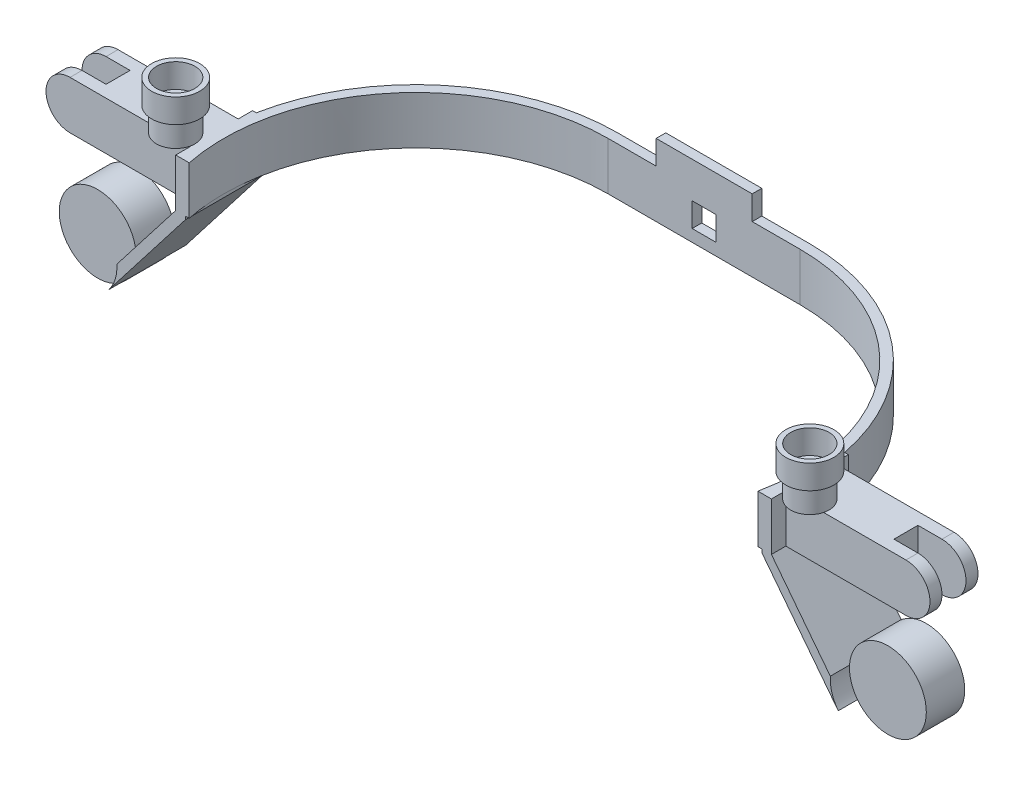
from build123d import *

# Parameters (mm, degrees)
EXTRUDE_1_DEPTH           = 20
SKETCH_18_W               = 10
SKETCH_18_H               = 10
CUT_EXTRUDE_6_DEPTH       = 10
SKETCH_20_W               = 40
SKETCH_20_H               = 4
EXTRUDE_5_DEPTH           = 10
SKETCH_22_R               = 8
EXTRUDE_7_DEPTH           = 10
EXTRUDE_7_2_DEPTH         = 10
SKETCH_23_R               = 10
SKETCH_23_R_2             = 8
EXTRUDE_8_DEPTH           = 10
EXTRUDE_8_2_DEPTH         = 10
SKETCH_8_W                = 4
SKETCH_8_H                = 32
SKETCH_11_W               = 4
SKETCH_11_H               = 32
SKETCH_25_W               = 246.903686524
SKETCH_25_H               = 75.06139437
CUT_EXTRUDE_7_DEPTH       = 30
SKETCH_26_W               = 20
SKETCH_26_H               = 20
EXTRUDE_9_DEPTH           = 60
SKETCH_28_W               = 20
SKETCH_28_H               = 20
EXTRUDE_10_DEPTH          = 60
CUT_EXTRUDE_8_DEPTH       = 60
SKETCH_29_W               = 20
SKETCH_29_H               = 25.723700811
SKETCH_29_H_2             = 33.540144271
CUT_EXTRUDE_9_DEPTH       = 5
SKETCH_30_R               = 16
CUT_EXTRUDE_10_DEPTH      = 19
CUT_EXTRUDE_10_DEPTH_BACK = 85
SKETCH_31_R               = 16
EXTRUDE_11_DEPTH          = 8


with BuildPart() as part:
    # 草图2 → 凸台-拉伸1 (new body)
    with BuildSketch(Plane(origin=(0, 0, 0), x_dir=(1, 0, 0), z_dir=(0, 1, 0))):
        with BuildLine():
            Line((-40, 84), (40, 84))
            ThreePointArc((40, 84), (124, 0), (40, -84))
            Line((40, -84), (-40, -84))
            ThreePointArc((-40, -84), (-124, 0), (-40, 84))
        make_face()
        with BuildLine():
            Line((-40, 80), (40, 80))
            ThreePointArc((40, 80), (120, 0), (40, -80))
            Line((40, -80), (-40, -80))
            ThreePointArc((-40, -80), (-120, 0), (-40, 80))
        make_face(mode=Mode.SUBTRACT)
    extrude(amount=EXTRUDE_1_DEPTH)

    # 草图18 → 切除-拉伸6 (cut)
    with BuildSketch(Plane(origin=(0, 0, -84), x_dir=(-1, 0, 0), z_dir=(0, 0, -1))):
        with Locations((0, 10)):
            Rectangle(SKETCH_18_W, SKETCH_18_H)
    extrude(amount=-CUT_EXTRUDE_6_DEPTH, mode=Mode.SUBTRACT)

    # 草图20 → 凸台-拉伸5 (add)
    with BuildSketch(Plane(origin=(0, 20, 0), x_dir=(1, 0, 0), z_dir=(0, 1, 0))):
        with Locations((0, 82)):
            Rectangle(SKETCH_20_W, SKETCH_20_H)
    extrude(amount=EXTRUDE_5_DEPTH)

    # 扫描1: sweep along a path in 草图9
    with BuildLine(Plane.XY) as sweep_1_path:
        Line((-124, 20), (-124, 0))
        Line((-124, 0), (-155, -40))
    # 草图8 → 扫描1 (sweep)
    with BuildSketch(Plane(origin=(0, 20, 0), x_dir=(1, 0, 0), z_dir=(0, 1, 0))):
        with Locations((-122, 0)):
            Rectangle(SKETCH_8_W, SKETCH_8_H)
    sweep(path=sweep_1_path.line, transition=Transition.RIGHT)

    # 扫描2: sweep along a path in 草图24
    with BuildLine(Plane.XY) as sweep_2_path:
        Line((124, 20), (124, 0))
        Line((124, 0), (155, -40))
    # 草图11 → 扫描2 (sweep)
    with BuildSketch(Plane(origin=(0, 20, 0), x_dir=(1, 0, 0), z_dir=(0, 1, 0))):
        with Locations((122, 0)):
            Rectangle(SKETCH_11_W, SKETCH_11_H)
    sweep(path=sweep_2_path.line, transition=Transition.RIGHT)

    # 草图25 → 切除-拉伸7 (cut)
    with BuildSketch(Plane(origin=(0, 20, 0), x_dir=(1, 0, 0), z_dir=(0, 1, 0))):
        with Locations((0.98973075, -53.530697185)):
            Rectangle(SKETCH_25_W, SKETCH_25_H)
    extrude(amount=-CUT_EXTRUDE_7_DEPTH, mode=Mode.SUBTRACT)



with BuildPart() as body_2:
    # 草图22 → 凸台-拉伸7 (new body)
    with BuildSketch(Plane(origin=(0, 20, 0), x_dir=(1, 0, 0), z_dir=(0, 1, 0))):
        with Locations((-132, -8)):
            Circle(SKETCH_22_R)
    extrude(amount=EXTRUDE_7_DEPTH)


with BuildPart() as body_3:
    # 草图22 → Extrude 7 2 (new body)
    with BuildSketch(Plane(origin=(0, 20, 0), x_dir=(1, 0, 0), z_dir=(0, 1, 0))):
        with Locations((132, -8)):
            Circle(SKETCH_22_R)
    extrude(amount=EXTRUDE_7_2_DEPTH)


with BuildPart() as body_4:
    # 草图23 → 凸台-拉伸8 (new body)
    with BuildSketch(Plane(origin=(0, 30, 0), x_dir=(1, 0, 0), z_dir=(0, 1, 0))):
        with Locations((-132, -8)):
            Circle(SKETCH_23_R)
        with Locations((-132, -8)):
            Circle(SKETCH_23_R_2, mode=Mode.SUBTRACT)
    extrude(amount=EXTRUDE_8_DEPTH)


with BuildPart() as body_5:
    # 草图23 → Extrude 8 2 (new body)
    with BuildSketch(Plane(origin=(0, 30, 0), x_dir=(1, 0, 0), z_dir=(0, 1, 0))):
        with Locations((132, -8)):
            Circle(SKETCH_23_R)
        with Locations((132, -8)):
            Circle(SKETCH_23_R_2, mode=Mode.SUBTRACT)
    extrude(amount=EXTRUDE_8_2_DEPTH)


with BuildPart() as part_1:
    add(part.part)

    add(body_2.part)  # 凸台-拉伸9 merges body 2
    # 草图26 → 凸台-拉伸9 (add)
    with BuildSketch(Plane.ZY.offset(124)):
        with Locations((0, 10)):
            Rectangle(SKETCH_26_W, SKETCH_26_H)
    extrude(amount=EXTRUDE_9_DEPTH)


    add(body_3.part)  # 凸台-拉伸10 merges body 3
    # 草图28 → 凸台-拉伸10 (add)
    with BuildSketch(Plane(origin=(124, 0, 0), x_dir=(0, 0, -1), z_dir=(1, 0, 0))):
        with Locations((0, 10)):
            Rectangle(SKETCH_28_W, SKETCH_28_H)
    extrude(amount=EXTRUDE_10_DEPTH)

    # 草图27 → 切除-拉伸8 (cut)
    with BuildSketch(Plane.XY.offset(10)):
        with BuildLine():
            Line((-174, 20), (-189, 20))
            Line((-189, 20), (-189, 0))
            Line((-189, 0), (-174, 0))
            ThreePointArc((-174, 0), (-184, 10), (-174, 20))
        make_face()
        with BuildLine():
            Line((174, 20), (191.961940959, 20))
            Line((191.961940959, 20), (191.961940959, 0))
            Line((191.961940959, 0), (174, 0))
            ThreePointArc((174, 0), (184, 10), (174, 20))
        make_face()
    extrude(amount=-CUT_EXTRUDE_8_DEPTH, mode=Mode.SUBTRACT)

    # 草图29 → 切除-拉伸9 (cut, symmetric)
    with BuildSketch(Plane.XY):
        with Locations((-174, 8.750781757)):
            Rectangle(SKETCH_29_W, SKETCH_29_H)
        with Locations((174, 7.12005993)):
            Rectangle(SKETCH_29_W, SKETCH_29_H_2)
    extrude(amount=CUT_EXTRUDE_9_DEPTH, both=True, mode=Mode.SUBTRACT)

    # 草图30 → 切除-拉伸10 (cut, two sides)
    with BuildSketch(Plane.XY) as cut_extrude_10_sk:
        with Locations((-164.484980626, -32.649140015)):
            Circle(SKETCH_30_R)
        with Locations((164.484980626, -32.649140015)):
            Circle(SKETCH_30_R)
    extrude(amount=CUT_EXTRUDE_10_DEPTH, mode=Mode.SUBTRACT)
    extrude(cut_extrude_10_sk.sketch, amount=-CUT_EXTRUDE_10_DEPTH_BACK, mode=Mode.SUBTRACT)

    # 草图31 → 凸台-拉伸11 (add, symmetric)
    with BuildSketch(Plane.XY):
        with Locations((-164.484980626, -32.649140015)):
            Circle(SKETCH_31_R)
        with Locations((164.484980626, -32.649140015)):
            Circle(SKETCH_31_R)
    extrude(amount=EXTRUDE_11_DEPTH, both=True)


solid = Compound([body_4.part, body_5.part, part_1.part])
